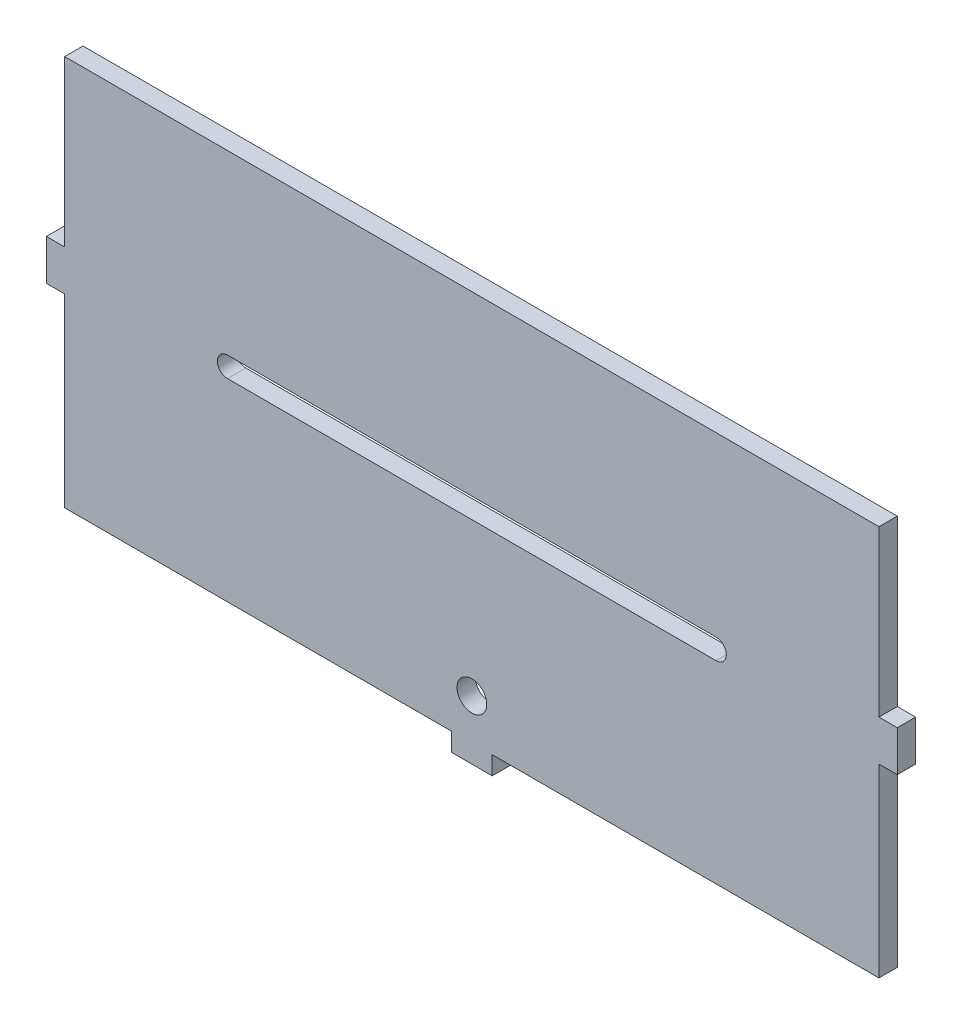
from build123d import *

# Parameters (mm, degrees)
BOSS_EXTRUDE1_DEPTH     = 5.715
CUT_EXTRUDE1_DEPTH      = 6.715
SKETCH4_R               = 4.6355
CUT_EXTRUDE2_DEPTH      = 1
CUT_EXTRUDE2_DEPTH_BACK = 6.715
SKETCH5_W               = 254
SKETCH5_H               = 5.08
CUT_EXTRUDE3_DEPTH      = 6.715


with BuildPart() as part:
    # Sketch1 → Boss-Extrude1 (new body)
    with BuildSketch(Plane.XY):
        Polygon((6.35, -63.5), (127, -63.5), (127, -5.715), (132.715, -5.715), (132.715, 6.985), (127, 6.985), (127, 63.5), (-127, 63.5), (-127, 6.985), (-132.715, 6.985), (-132.715, -5.715), (-127, -5.715), (-127, -63.5), (-6.35, -63.5), (-6.35, -69.215), (6.35, -69.215), align=None)
    extrude(amount=BOSS_EXTRUDE1_DEPTH)

    # Sketch2 → Cut-Extrude1 (cut, through all)
    with BuildSketch(Plane.XY.offset(5.715)):
        with BuildLine():
            Line((76.2, -3.175), (-76.2, -3.175))
            ThreePointArc((-76.2, -3.175), (-79.375, 0), (-76.2, 3.175))
            Line((-76.2, 3.175), (76.2, 3.175))
            ThreePointArc((76.2, 3.175), (79.375, 0), (76.2, -3.175))
        make_face()
    extrude(amount=-CUT_EXTRUDE1_DEPTH, mode=Mode.SUBTRACT)

    # Sketch4 → Cut-Extrude2 (cut, two sides)
    with BuildSketch(Plane.XY.offset(5.715)) as cut_extrude2_sk:
        with Locations((0, -50.8)):
            Circle(SKETCH4_R)
    extrude(amount=CUT_EXTRUDE2_DEPTH, mode=Mode.SUBTRACT)
    extrude(cut_extrude2_sk.sketch, amount=-CUT_EXTRUDE2_DEPTH_BACK, mode=Mode.SUBTRACT)

    # Sketch5 → Cut-Extrude3 (cut, through all)
    with BuildSketch(Plane.XY.offset(5.715)):
        with Locations((0, 60.96)):
            Rectangle(SKETCH5_W, SKETCH5_H)
    extrude(amount=-CUT_EXTRUDE3_DEPTH, mode=Mode.SUBTRACT)


solid = part.part
